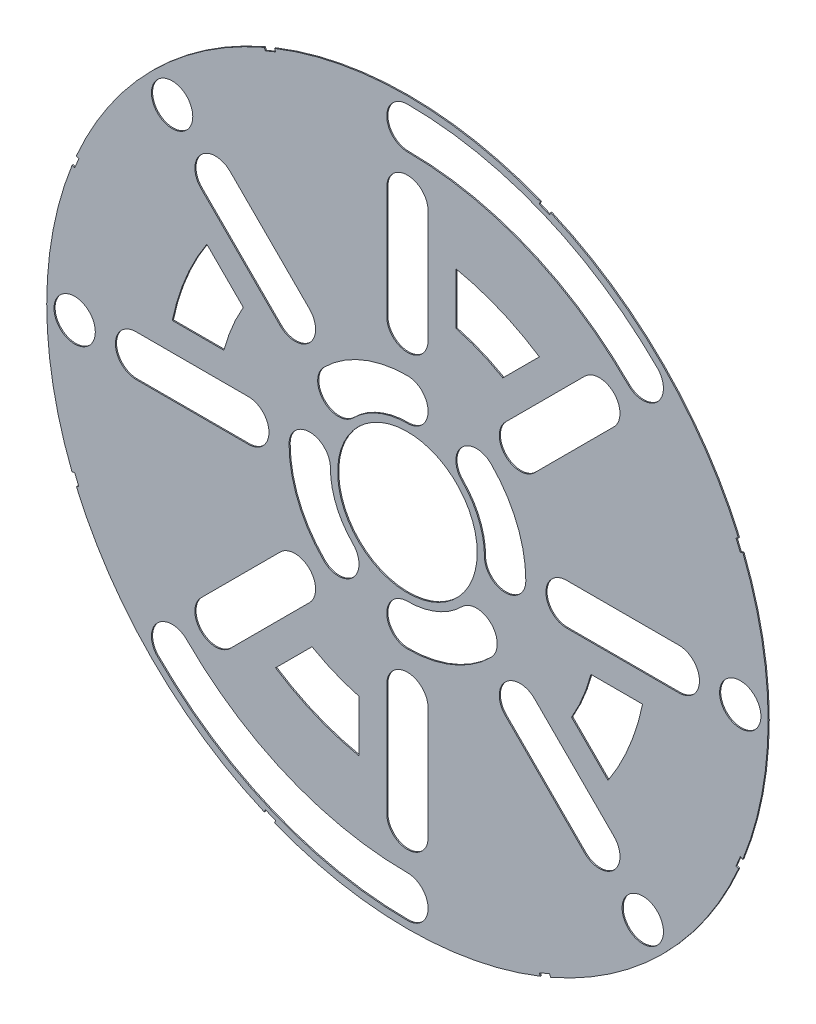
from build123d import *

# Parameters (mm, degrees)
SKETCH4_R           = 82.042
BOSS_EXTRUDE2_DEPTH = 0.254
SKETCH5_R           = 15.875
CUT_EXTRUDE5_DEPTH  = 1.254
CUT_EXTRUDE11_DEPTH = 1.254
SKETCH9_R           = 4.699
CUT_EXTRUDE12_DEPTH = 1.254
CUT_EXTRUDE14_DEPTH = 1.254


with BuildPart() as part:
    # Sketch4 → Boss-Extrude2 (new body)
    with BuildSketch(Plane.XY):
        Circle(SKETCH4_R)
    extrude(amount=BOSS_EXTRUDE2_DEPTH)

    # Sketch5 → Cut-Extrude5 (cut, through all)
    with BuildSketch(Plane.XY.offset(0.254)):
        Circle(SKETCH5_R)
    extrude(amount=-CUT_EXTRUDE5_DEPTH, mode=Mode.SUBTRACT)

    # Sketch8 → Cut-Extrude11 (cut, through all)
    with BuildSketch(Plane.XY.offset(0.254)):
        Polygon((76.869596069, 30.465791131), (75.89758015, 32.812445144), (74.724253144, 32.326437185), (75.696269062, 29.979783172), align=None)
        Polygon((-30.465791131, 76.869596069), (-32.812445144, 75.89758015), (-32.326437185, 74.724253144), (-29.979783172, 75.696269062), align=None)
        Polygon((-75.89758015, 32.812445144), (-76.869596069, 30.465791131), (-75.696269062, 29.979783172), (-74.724253144, 32.326437185), align=None)
        Polygon((-76.869596069, -30.465791131), (-75.89758015, -32.812445144), (-74.724253144, -32.326437185), (-75.696269062, -29.979783172), align=None)
        Polygon((-32.812445144, -75.89758015), (-30.465791131, -76.869596069), (-29.979783172, -75.696269062), (-32.326437185, -74.724253144), align=None)
        Polygon((30.465791131, -76.869596069), (32.812445144, -75.89758015), (32.326437185, -74.724253144), (29.979783172, -75.696269062), align=None)
        Polygon((75.89758015, -32.812445144), (76.869596069, -30.465791131), (75.696269062, -29.979783172), (74.724253144, -32.326437185), align=None)
        Polygon((32.812445144, 75.89758015), (30.465791131, 76.869596069), (29.979783172, 75.696269062), (32.326437185, 74.724253144), align=None)
    extrude(amount=-CUT_EXTRUDE11_DEPTH, mode=Mode.SUBTRACT)

    # Sketch9 → Cut-Extrude12 (cut, through all)
    with BuildSketch(Plane.XY.offset(0.254)):
        with Locations((22.225, 0)):
            Circle(SKETCH9_R)
        with Locations((36.195, 0)):
            Circle(SKETCH9_R)
        with Locations((61.722, 0)):
            Circle(SKETCH9_R)
        with Locations((75.692, 0)):
            Circle(SKETCH9_R)
        with Locations((15.715448212, -15.715448212)):
            Circle(SKETCH9_R)
        with Locations((25.593729945, -25.593729945)):
            Circle(SKETCH9_R)
        with Locations((43.644044748, -43.644044748)):
            Circle(SKETCH9_R)
        with Locations((53.522326482, -53.522326482)):
            Circle(SKETCH9_R)
        with Locations((0, -22.225)):
            Circle(SKETCH9_R)
        with Locations((0, -36.195)):
            Circle(SKETCH9_R)
        with Locations((0, -61.722)):
            Circle(SKETCH9_R)
        with Locations((0, -75.692)):
            Circle(SKETCH9_R)
        with Locations((-15.715448212, -15.715448212)):
            Circle(SKETCH9_R)
        with Locations((-25.593729945, -25.593729945)):
            Circle(SKETCH9_R)
        with Locations((-43.644044748, -43.644044748)):
            Circle(SKETCH9_R)
        with Locations((-53.522326482, -53.522326482)):
            Circle(SKETCH9_R)
        with Locations((-22.225, 0)):
            Circle(SKETCH9_R)
        with Locations((-36.195, 0)):
            Circle(SKETCH9_R)
        with Locations((-61.722, 0)):
            Circle(SKETCH9_R)
        with Locations((-75.692, 0)):
            Circle(SKETCH9_R)
        with Locations((-15.715448212, 15.715448212)):
            Circle(SKETCH9_R)
        with Locations((-25.593729945, 25.593729945)):
            Circle(SKETCH9_R)
        with Locations((-43.644044748, 43.644044748)):
            Circle(SKETCH9_R)
        with Locations((-53.522326482, 53.522326482)):
            Circle(SKETCH9_R)
        with Locations((0, 22.225)):
            Circle(SKETCH9_R)
        with Locations((0, 36.195)):
            Circle(SKETCH9_R)
        with Locations((0, 61.722)):
            Circle(SKETCH9_R)
        with Locations((0, 75.692)):
            Circle(SKETCH9_R)
        with Locations((15.715448212, 15.715448212)):
            Circle(SKETCH9_R)
        with Locations((25.593729945, 25.593729945)):
            Circle(SKETCH9_R)
        with Locations((43.644044748, 43.644044748)):
            Circle(SKETCH9_R)
        with Locations((53.522326482, 53.522326482)):
            Circle(SKETCH9_R)
    extrude(amount=-CUT_EXTRUDE12_DEPTH, mode=Mode.SUBTRACT)

    # Sketch11 → Cut-Extrude14 (cut, through all)
    with BuildSketch(Plane.XY.offset(0.254)):
        with BuildLine():
            Line((36.195, 4.699), (61.722, 4.699))
            ThreePointArc((61.722, 4.699), (66.421, 0), (61.722, -4.699))
            Line((61.722, -4.699), (36.195, -4.699))
            ThreePointArc((36.195, -4.699), (31.496, 0), (36.195, 4.699))
        make_face()
        with BuildLine():
            Line((28.91642471, -22.27103518), (46.966739513, -40.321349984))
            ThreePointArc((46.966739513, -40.321349984), (46.966739513, -46.966739513), (40.321349984, -46.966739513))
            Line((40.321349984, -46.966739513), (22.27103518, -28.91642471))
            ThreePointArc((22.27103518, -28.91642471), (22.27103518, -22.27103518), (28.91642471, -22.27103518))
        make_face()
        with BuildLine():
            Line((4.699, -36.195), (4.699, -61.722))
            ThreePointArc((4.699, -61.722), (0, -66.421), (-4.699, -61.722))
            Line((-4.699, -61.722), (-4.699, -36.195))
            ThreePointArc((-4.699, -36.195), (0, -31.496), (4.699, -36.195))
        make_face()
        with BuildLine():
            Line((-22.27103518, -28.91642471), (-40.321349984, -46.966739513))
            ThreePointArc((-40.321349984, -46.966739513), (-46.966739513, -46.966739513), (-46.966739513, -40.321349984))
            Line((-46.966739513, -40.321349984), (-28.91642471, -22.27103518))
            ThreePointArc((-28.91642471, -22.27103518), (-22.27103518, -22.27103518), (-22.27103518, -28.91642471))
        make_face()
        with BuildLine():
            Line((-36.195, -4.699), (-61.722, -4.699))
            ThreePointArc((-61.722, -4.699), (-66.421, 0), (-61.722, 4.699))
            Line((-61.722, 4.699), (-36.195, 4.699))
            ThreePointArc((-36.195, 4.699), (-31.496, 0), (-36.195, -4.699))
        make_face()
        with BuildLine():
            Line((-28.91642471, 22.27103518), (-46.966739513, 40.321349984))
            ThreePointArc((-46.966739513, 40.321349984), (-46.966739513, 46.966739513), (-40.321349984, 46.966739513))
            Line((-40.321349984, 46.966739513), (-22.27103518, 28.91642471))
            ThreePointArc((-22.27103518, 28.91642471), (-22.27103518, 22.27103518), (-28.91642471, 22.27103518))
        make_face()
        with BuildLine():
            Line((-4.699, 36.195), (-4.699, 61.722))
            ThreePointArc((-4.699, 61.722), (0, 66.421), (4.699, 61.722))
            Line((4.699, 61.722), (4.699, 36.195))
            ThreePointArc((4.699, 36.195), (0, 31.496), (-4.699, 36.195))
        make_face()
        with BuildLine():
            Line((22.27103518, 28.91642471), (40.321349984, 46.966739513))
            ThreePointArc((40.321349984, 46.966739513), (46.966739513, 46.966739513), (46.966739513, 40.321349984))
            Line((46.966739513, 40.321349984), (28.91642471, 22.27103518))
            ThreePointArc((28.91642471, 22.27103518), (22.27103518, 22.27103518), (22.27103518, 28.91642471))
        make_face()
        with BuildLine():
            Line((11.049, 41.742448407), (11.049, 53.480573099))
            ThreePointArc((11.049, 53.480573099), (20.898342241, 50.45306127), (30.003653075, 45.629298725))
            Line((30.003653075, 45.629298725), (21.703545506, 37.329191157))
            ThreePointArc((21.703545506, 37.329191157), (16.52427061, 39.893118214), (11.049, 41.742448407))
        make_face()
        with BuildLine():
            Line((37.329191157, -21.703545506), (45.629298725, -30.003653075))
            ThreePointArc((45.629298725, -30.003653075), (50.45306127, -20.898342241), (53.480573099, -11.049))
            Line((53.480573099, -11.049), (41.742448407, -11.049))
            ThreePointArc((41.742448407, -11.049), (39.893118214, -16.52427061), (37.329191157, -21.703545506))
        make_face()
        with BuildLine():
            Line((-21.703545506, -37.329191157), (-30.003653075, -45.629298725))
            ThreePointArc((-30.003653075, -45.629298725), (-20.898342241, -50.45306127), (-11.049, -53.480573099))
            Line((-11.049, -53.480573099), (-11.049, -41.742448407))
            ThreePointArc((-11.049, -41.742448407), (-16.52427061, -39.893118214), (-21.703545506, -37.329191157))
        make_face()
        with BuildLine():
            Line((-37.329191157, 21.703545506), (-45.629298725, 30.003653075))
            ThreePointArc((-45.629298725, 30.003653075), (-50.45306127, 20.898342241), (-53.480573099, 11.049))
            Line((-53.480573099, 11.049), (-41.742448407, 11.049))
            ThreePointArc((-41.742448407, 11.049), (-39.893118214, 16.52427061), (-37.329191157, 21.703545506))
        make_face()
        with BuildLine():
            ThreePointArc((26.924, 0), (24.874532533, 10.303368733), (19.038142977, 19.038142977))
            ThreePointArc((19.038142977, 19.038142977), (12.392753447, 19.038142977), (12.392753447, 12.392753447))
            ThreePointArc((12.392753447, 12.392753447), (16.191912687, 6.706909836), (17.526, 0))
            ThreePointArc((17.526, 0), (22.225, -4.699), (26.924, 0))
        make_face()
        with BuildLine():
            ThreePointArc((0, -26.924), (10.303368733, -24.874532533), (19.038142977, -19.038142977))
            ThreePointArc((19.038142977, -19.038142977), (19.038142977, -12.392753447), (12.392753447, -12.392753447))
            ThreePointArc((12.392753447, -12.392753447), (6.706909836, -16.191912687), (0, -17.526))
            ThreePointArc((0, -17.526), (-4.699, -22.225), (0, -26.924))
        make_face()
        with BuildLine():
            ThreePointArc((-26.924, 0), (-24.874532533, -10.303368733), (-19.038142977, -19.038142977))
            ThreePointArc((-19.038142977, -19.038142977), (-12.392753447, -19.038142977), (-12.392753447, -12.392753447))
            ThreePointArc((-12.392753447, -12.392753447), (-16.191912687, -6.706909836), (-17.526, 0))
            ThreePointArc((-17.526, 0), (-22.225, 4.699), (-26.924, 0))
        make_face()
        with BuildLine():
            ThreePointArc((0, 26.924), (-10.303368733, 24.874532533), (-19.038142977, 19.038142977))
            ThreePointArc((-19.038142977, 19.038142977), (-19.038142977, 12.392753447), (-12.392753447, 12.392753447))
            ThreePointArc((-12.392753447, 12.392753447), (-6.706909836, 16.191912687), (0, 17.526))
            ThreePointArc((0, 17.526), (4.699, 22.225), (0, 26.924))
        make_face()
        with BuildLine():
            ThreePointArc((56.845021246, 56.845021246), (30.764303811, 74.271599498), (0, 80.391))
            ThreePointArc((0, 80.391), (-4.699, 75.692), (0, 70.993))
            ThreePointArc((0, 70.993), (27.167844914, 65.588979652), (50.199631717, 50.199631717))
            ThreePointArc((50.199631717, 50.199631717), (56.845021246, 50.199631717), (56.845021246, 56.845021246))
        make_face()
        with BuildLine():
            ThreePointArc((-56.845021246, -56.845021246), (-30.764303811, -74.271599498), (0, -80.391))
            ThreePointArc((0, -80.391), (4.699, -75.692), (0, -70.993))
            ThreePointArc((0, -70.993), (-27.167844914, -65.588979652), (-50.199631717, -50.199631717))
            ThreePointArc((-50.199631717, -50.199631717), (-56.845021246, -50.199631717), (-56.845021246, -56.845021246))
        make_face()
    extrude(amount=-CUT_EXTRUDE14_DEPTH, mode=Mode.SUBTRACT)


solid = part.part
